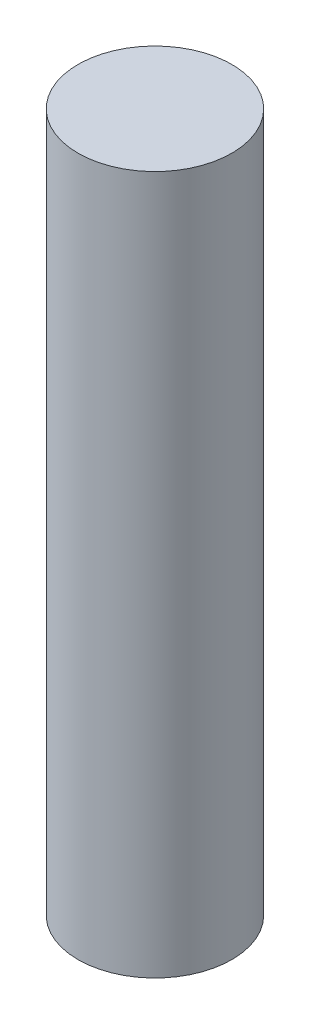
from build123d import *

# Parameters (mm, degrees)
SKETCH1_R           = 6.35
BOSS_EXTRUDE1_DEPTH = 57.658


with BuildPart() as part:
    # Sketch1 → Boss-Extrude1 (new body)
    with BuildSketch(Plane(origin=(0, 0, 0), x_dir=(1, 0, 0), z_dir=(0, 1, 0))):
        Circle(SKETCH1_R)
    extrude(amount=BOSS_EXTRUDE1_DEPTH)


solid = part.part
